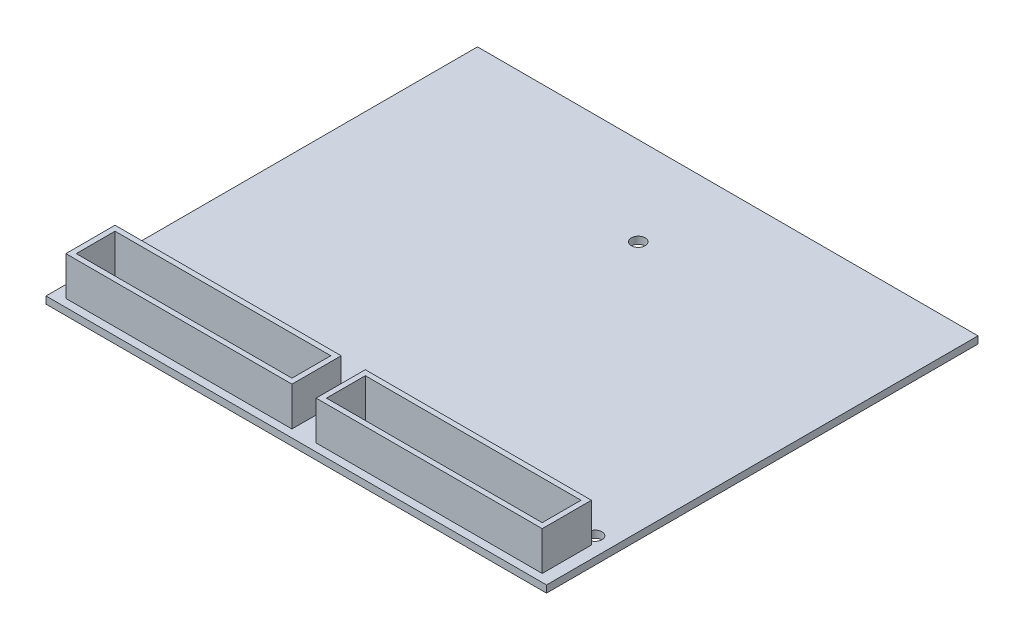
from build123d import *

# Parameters (mm, degrees)
SKETCH1_W                = 116
SKETCH1_H                = 100
BOSS_EXTRUDE1_DEPTH      = 1.65
M3_CLEARANCE_HOLE1_D     = 3.2
M3_CLEARANCE_HOLE1_DEPTH = 20
M3_CLEARANCE_HOLE1_TIP   = 0.96137699
SKETCH6_W                = 52.4
SKETCH6_H                = 11.4
SKETCH6_W_2              = 50
SKETCH6_H_2              = 9
EXTRUDE_THIN1_DEPTH      = 9


with BuildPart() as part:
    # Sketch1 → Boss-Extrude1 (new body)
    with BuildSketch(Plane(origin=(0, 0, 0), x_dir=(1, 0, 0), z_dir=(0, 1, 0))):
        with Locations((58, 50)):
            Rectangle(SKETCH1_W, SKETCH1_H)
    extrude(amount=BOSS_EXTRUDE1_DEPTH)

    # M3 Clearance Hole1
    with Locations(Plane(origin=(0, 1.65, 0), x_dir=(1, 0, 0), z_dir=(0, 1, 0))):
        with Locations((4, 15.5), (111.75, 15.5), (57.75, 79.5)):
            Hole(M3_CLEARANCE_HOLE1_D / 2, depth=M3_CLEARANCE_HOLE1_DEPTH)
            with Locations((0, 0, -(M3_CLEARANCE_HOLE1_DEPTH + M3_CLEARANCE_HOLE1_TIP / 2))):  # 118° drill point
                Cone(0, M3_CLEARANCE_HOLE1_D / 2, M3_CLEARANCE_HOLE1_TIP, mode=Mode.SUBTRACT)

    # Sketch6 → Extrude-Thin1 (add)
    with BuildSketch(Plane(origin=(0, 1.65, 0), x_dir=(1, 0, 0), z_dir=(0, 1, 0))):
        with Locations((29, 7.5)):
            Rectangle(SKETCH6_W, SKETCH6_H)
        with Locations((29, 7.5)):
            Rectangle(SKETCH6_W_2, SKETCH6_H_2, mode=Mode.SUBTRACT)
        with Locations((87, 7.5)):
            Rectangle(SKETCH6_W, SKETCH6_H)
        with Locations((87, 7.5)):
            Rectangle(SKETCH6_W_2, SKETCH6_H_2, mode=Mode.SUBTRACT)
    extrude(amount=EXTRUDE_THIN1_DEPTH)


solid = part.part
